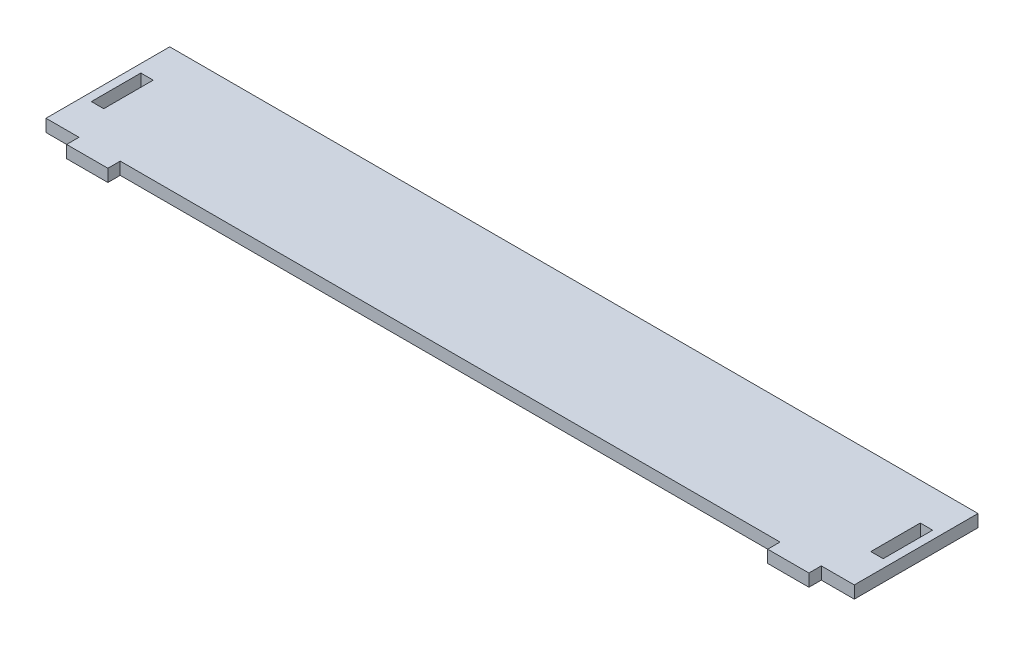
from build123d import *

# Parameters (mm, degrees)
SKETCH_1_W      = 3
SKETCH_1_H      = 12
EXTRUDE_1_DEPTH = 3


with BuildPart() as part:
    # 草图1 → 凸台-拉伸1 (new body)
    with BuildSketch(Plane(origin=(0, 0, 0), x_dir=(1, 0, 0), z_dir=(0, 1, 0))):
        Polygon((-8, 30), (-8, 0), (-3, 0), (0, 0), (0, -3), (10, -3), (10, 0), (170, 0), (170, -3), (180, -3), (180, 0), (183, 0), (188, 0), (188, 30), (183, 30), (180, 30), (0, 30), (-3, 30), align=None)
        with Locations((184.5, 15)):
            Rectangle(SKETCH_1_W, SKETCH_1_H, mode=Mode.SUBTRACT)
        with Locations((-4.5, 15)):
            Rectangle(SKETCH_1_W, SKETCH_1_H, mode=Mode.SUBTRACT)
    extrude(amount=EXTRUDE_1_DEPTH)


solid = part.part
